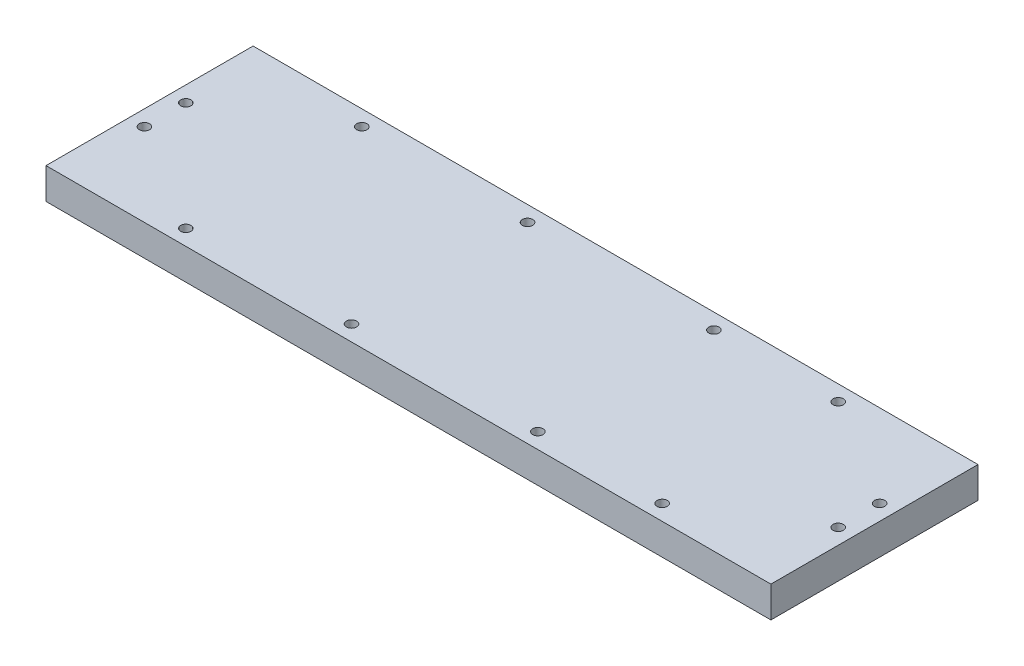
from build123d import *

# Parameters (mm, degrees)
SKETCH1_W           = 444.5
SKETCH1_H           = 127
BOSS_EXTRUDE1_DEPTH = 19.05
SKETCH2_R           = 3.175
CUT_EXTRUDE1_DEPTH  = 12.7
SKETCH3_R           = 3.175
CUT_EXTRUDE2_DEPTH  = 12.7
SKETCH4_R           = 1.5875
CUT_EXTRUDE3_DEPTH  = 6.35


with BuildPart() as part:
    # Sketch1 → Boss-Extrude1 (new body)
    with BuildSketch(Plane(origin=(0, 0, 0), x_dir=(1, 0, 0), z_dir=(0, 1, 0))):
        Rectangle(SKETCH1_W, SKETCH1_H)
    extrude(amount=BOSS_EXTRUDE1_DEPTH)

    # Sketch2 → Cut-Extrude1 (cut)
    with BuildSketch(Plane(origin=(0, 19.05, 0), x_dir=(1, 0, 0), z_dir=(0, 1, 0))):
        with Locations((-146.05, -53.975)):
            Circle(SKETCH2_R)
        with Locations((-44.45, -53.975)):
            Circle(SKETCH2_R)
        with Locations((69.85, -53.975)):
            Circle(SKETCH2_R)
        with Locations((146.05, -53.975)):
            Circle(SKETCH2_R)
    cut_extrude1 = extrude(amount=-CUT_EXTRUDE1_DEPTH, mode=Mode.SUBTRACT)

    # Mirror1: Cut-Extrude1 across plane
    add(cut_extrude1.mirror(Plane.XY), mode=Mode.SUBTRACT)

    # Sketch3 → Cut-Extrude2 (cut)
    with BuildSketch(Plane(origin=(0, 19.05, 0), x_dir=(1, 0, 0), z_dir=(0, 1, 0))):
        with Locations((-212.725, 12.7)):
            Circle(SKETCH3_R)
        with Locations((-212.725, -12.7)):
            Circle(SKETCH3_R)
    cut_extrude2 = extrude(amount=-CUT_EXTRUDE2_DEPTH, mode=Mode.SUBTRACT)

    # Mirror3: Cut-Extrude2 across plane
    add(cut_extrude2.mirror(Plane(origin=(0, 0, 0), x_dir=(0, 0, 1), z_dir=(1, 0, 0))), mode=Mode.SUBTRACT)

    # Sketch4 → Cut-Extrude3 (cut)
    with BuildSketch(Plane.XZ):
        with Locations((-95.25, -31.75)):
            Circle(SKETCH4_R)
        with Locations((0, -31.75)):
            Circle(SKETCH4_R)
        with Locations((95.25, -31.75)):
            Circle(SKETCH4_R)
    cut_extrude3 = extrude(amount=-CUT_EXTRUDE3_DEPTH, mode=Mode.SUBTRACT)

    # Mirror4: Cut-Extrude3 across plane
    add(cut_extrude3.mirror(Plane.XY), mode=Mode.SUBTRACT)


solid = part.part
